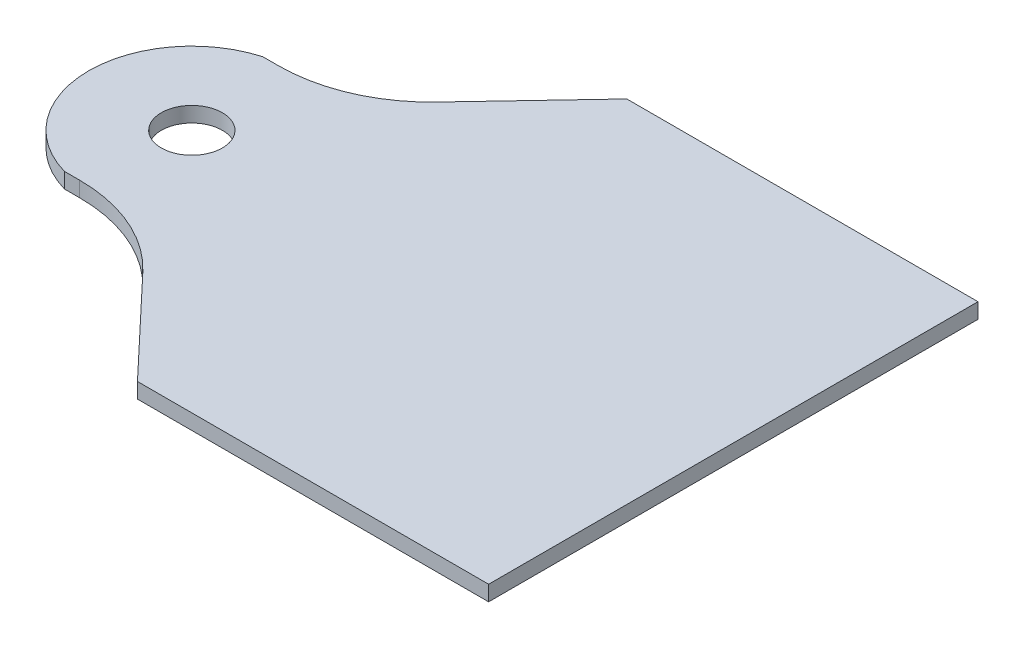
from build123d import *

# Parameters (mm, degrees)
SKETCH_1_R      = 4
EXTRUDE_1_DEPTH = 2


with BuildPart() as part:
    # 草图1 → 凸台-拉伸1 (new body)
    with BuildSketch(Plane(origin=(0, 0, 0), x_dir=(1, 0, 0), z_dir=(0, 1, 0))):
        with BuildLine():
            Line((-49.618188819, -13), (-51.618188819, -13))
            ThreePointArc((-51.618188819, -13), (-61.441082992, 0), (-51.618188819, 13))
            Line((-51.618188819, 13), (-49.618188819, 13))
            ThreePointArc((-49.618188819, 13), (-41.703538748, 14.632683531), (-35.08110056, 19.264168574))
            Line((-35.08110056, 19.264168574), (-23, 32.05))
            Line((-23, 32.05), (23, 32.05))
            Line((23, 32.05), (23, -32.05))
            Line((23, -32.05), (-23, -32.05))
            Line((-23, -32.05), (-35.08110056, -19.264168574))
            ThreePointArc((-35.08110056, -19.264168574), (-41.703538748, -14.632683531), (-49.618188819, -13))
        make_face()
        with Locations((-47.927283228, 0)):
            Circle(SKETCH_1_R, mode=Mode.SUBTRACT)
    extrude(amount=EXTRUDE_1_DEPTH)


solid = part.part
